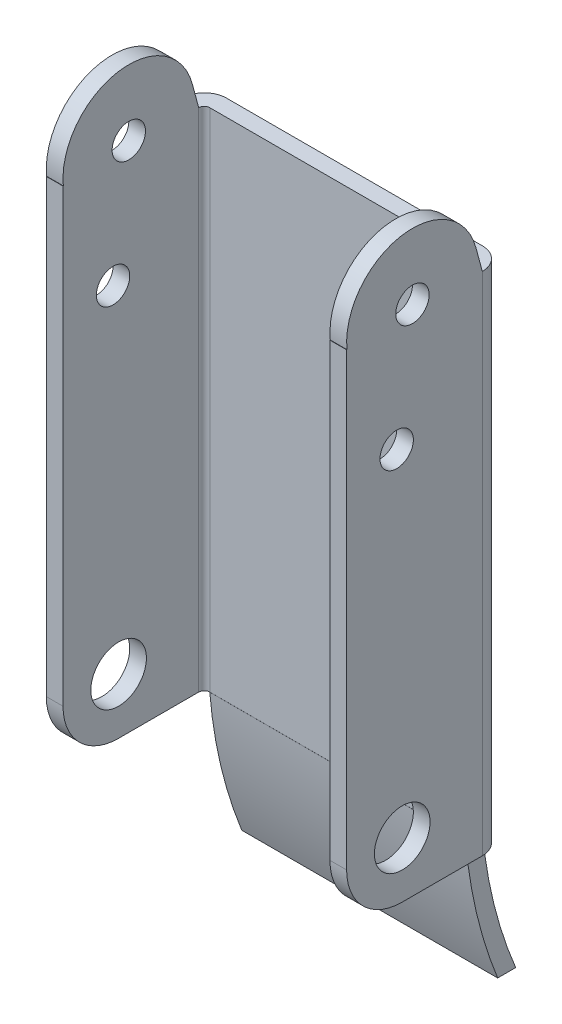
from build123d import *

# Parameters (mm, degrees)
BOSS_EXTRUDE1_DEPTH      = 52
SKETCH2_R                = 2.5
SKETCH2_R_2              = 1.5
CUT_EXTRUDE1_DEPTH       = 26
BOSS_EXTRUDE2_DEPTH      = 11.5
BOSS_EXTRUDE2_DEPTH_BACK = 11.5


with BuildPart() as part:
    # Sketch1 → Boss-Extrude1 (new body)
    with BuildSketch(Plane(origin=(0, 0, 0), x_dir=(1, 0, 0), z_dir=(0, 1, 0))):
        with BuildLine():
            Line((13.5, 0), (13.5, 12.2))
            ThreePointArc((13.5, 12.2), (12.914213562, 13.614213562), (11.5, 14.2))
            Line((11.5, 14.2), (-11.5, 14.2))
            ThreePointArc((-11.5, 14.2), (-12.914213562, 13.614213562), (-13.5, 12.2))
            Line((-13.5, 12.2), (-13.5, 0))
            Line((-13.5, 0), (-12, 0))
            Line((-12, 0), (-12, 12.2))
            ThreePointArc((-12, 12.2), (-11.853553391, 12.553553391), (-11.5, 12.7))
            Line((-11.5, 12.7), (11.5, 12.7))
            ThreePointArc((11.5, 12.7), (11.853553391, 12.553553391), (12, 12.2))
            Line((12, 12.2), (12, 0))
            Line((12, 0), (13.5, 0))
        make_face()
    extrude(amount=BOSS_EXTRUDE1_DEPTH)

    # Sketch2 → Cut-Extrude1 (cut, symmetric)
    with BuildSketch(Plane(origin=(0, 0, 0), x_dir=(0, 0, -1), z_dir=(1, 0, 0))):
        with Locations((5, 5)):
            Circle(SKETCH2_R)
        with Locations((5.917597774, 46.082402226)):
            Circle(SKETCH2_R_2)
        with Locations((4.5, 35.5)):
            Circle(SKETCH2_R_2)
        with BuildLine():
            Line((12.2, 45.5), (11.633558293, 47.613989232))
            ThreePointArc((11.633558293, 47.613989232), (4.857073421, 51.904193317), (0.028729372, 45.5))
            Line((0.028729372, 45.5), (-2.330829718, 45.5))
            Line((-2.330829718, 45.5), (-2.330829718, 58.046352069))
            Line((-2.330829718, 58.046352069), (16.335993039, 58.046352069))
            Line((16.335993039, 58.046352069), (16.335993039, 45.5))
            Line((16.335993039, 45.5), (12.2, 45.5))
        make_face()
        with BuildLine():
            Line((0, 5), (0, 0))
            Line((0, 0), (5, 0))
            ThreePointArc((5, 0), (1.464466094, 1.464466094), (0, 5))
        make_face()
    extrude(amount=CUT_EXTRUDE1_DEPTH, both=True, mode=Mode.SUBTRACT)

    # Sketch4 → Boss-Extrude2 (add, two sides)
    with BuildSketch(Plane(origin=(0, 0, 0), x_dir=(0, 0, -1), z_dir=(1, 0, 0))) as boss_extrude2_sk:
        with BuildLine():
            Line((12.694645471, 0), (14.2, 0))
            ThreePointArc((14.2, 0), (15.225683929, -6.216635866), (17.200004735, -12.2))
            Line((17.200004735, -12.2), (15.579003919, -12.2))
            ThreePointArc((15.579003919, -12.2), (13.680583201, -6.207865902), (12.694645471, 0))
        make_face()
    extrude(amount=BOSS_EXTRUDE2_DEPTH)
    extrude(boss_extrude2_sk.sketch, amount=-BOSS_EXTRUDE2_DEPTH_BACK)


solid = part.part
